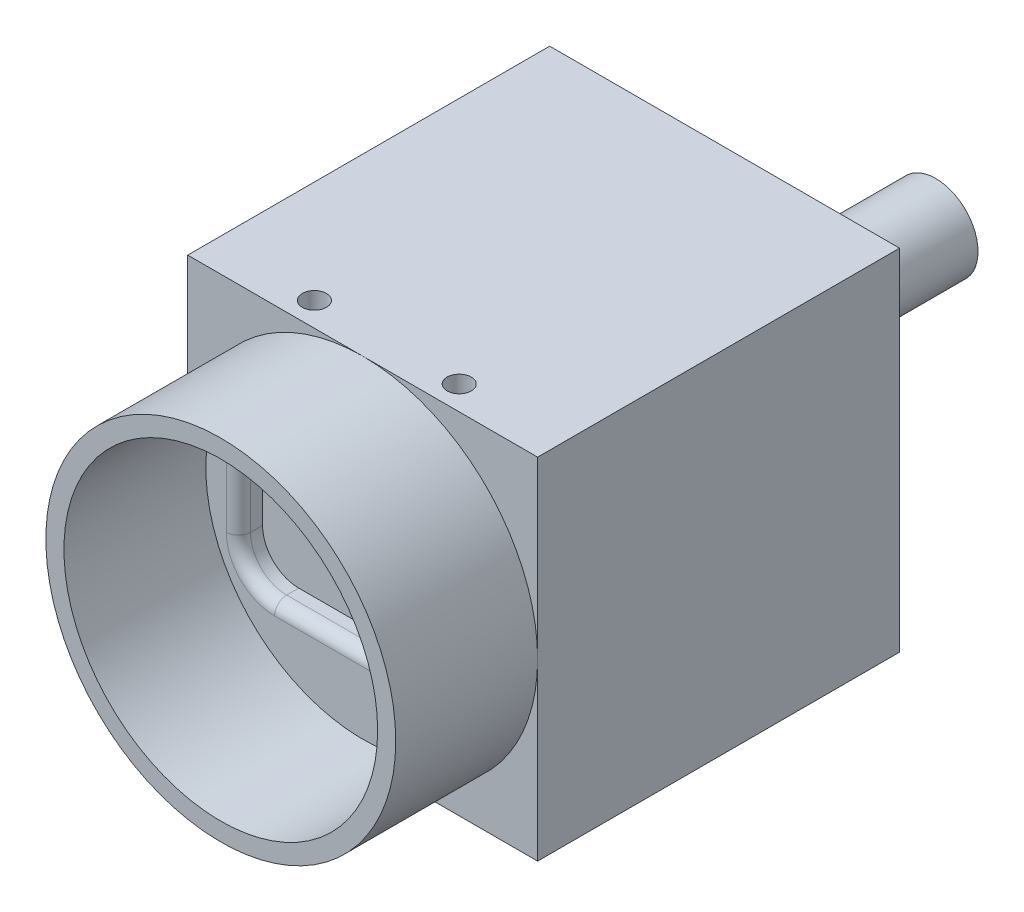
from build123d import *

# Parameters (mm, degrees)
SKETCH1_W           = 29
SKETCH1_H           = 29
BOSS_EXTRUDE1_DEPTH = 30
SKETCH2_R           = 14.5
SKETCH2_R_2         = 13
BOSS_EXTRUDE2_DEPTH = 11.76
SKETCH4_W           = 20.6
SKETCH4_H           = 13.6
CUT_EXTRUDE1_DEPTH  = 2
FILLET1_R           = 3
FILLET2_R           = 1
SKETCH5_R           = 3.5
SKETCH5_R_2         = 2.5
BOSS_EXTRUDE3_DEPTH = 8
SKETCH6_R           = 1
CUT_EXTRUDE2_DEPTH  = 3
SKETCH8_R           = 1.5
SKETCH8_R_2         = 1
CUT_EXTRUDE3_DEPTH  = 2
SKETCH9_W           = 22
SKETCH9_H           = 6
BOSS_EXTRUDE4_DEPTH = 1
SKETCH10_R          = 1
CUT_EXTRUDE4_DEPTH  = 2


with BuildPart() as part:
    # Sketch1 → Boss-Extrude1 (new body)
    with BuildSketch(Plane.XY):
        with Locations((-0.780453258, -3.943342776)):
            Rectangle(SKETCH1_W, SKETCH1_H)
    extrude(amount=BOSS_EXTRUDE1_DEPTH)

    # Sketch2 → Boss-Extrude2 (add)
    with BuildSketch(Plane.XY.offset(30)):
        with Locations((-0.780453258, -3.943342776)):
            Circle(SKETCH2_R)
        with Locations((-0.780453258, -3.943342776)):
            Circle(SKETCH2_R_2, mode=Mode.SUBTRACT)
    extrude(amount=BOSS_EXTRUDE2_DEPTH)

    # Sketch4 → Cut-Extrude1 (cut)
    with BuildSketch(Plane.XY.offset(30)):
        with Locations((-0.780453258, -3.943342776)):
            Rectangle(SKETCH4_W, SKETCH4_H)
    extrude(amount=-CUT_EXTRUDE1_DEPTH, mode=Mode.SUBTRACT)

    # Fillet1
    fillet1_edges = [part.edges().sort_by_distance(p)[0] for p in [
        (-11.080453258, -10.743342776, 29),
        (-11.080453258, 2.856657224, 29),
        (9.519546742, 2.856657224, 29),
        (9.519546742, -10.743342776, 29),
    ]]
    fillet(fillet1_edges, radius=FILLET1_R)

    # Fillet2
    fillet2_edges = [part.edges().sort_by_distance(p)[0] for p in [
        (-0.780453258, -10.743342776, 30),
        (-11.080453258, -3.943342776, 30),
        (9.519546742, -3.943342776, 30),
        (-0.780453258, 2.856657224, 30),
        (-10.201773601, -9.86466312, 30),
        (8.640867086, -9.86466312, 30),
        (8.640867086, 1.977977567, 30),
        (-10.201773601, 1.977977567, 30),
    ]]
    fillet(fillet2_edges, radius=FILLET2_R)

    # Sketch5 → Boss-Extrude3 (add)
    with BuildSketch(Plane(origin=(0, 0, 0), x_dir=(-1, 0, 0), z_dir=(0, 0, -1))):
        with Locations((-8.719546742, 5.556657224)):
            Circle(SKETCH5_R)
        with Locations((-8.719546742, 5.556657224)):
            Circle(SKETCH5_R_2, mode=Mode.SUBTRACT)
    extrude(amount=BOSS_EXTRUDE3_DEPTH)

    # Sketch6 → Cut-Extrude2 (cut)
    with BuildSketch(Plane(origin=(0, 10.556657224, 0), x_dir=(1, 0, 0), z_dir=(0, 1, 0))):
        with Locations((-6.780453258, -28)):
            Circle(SKETCH6_R)
        with Locations((5.219546742, -28)):
            Circle(SKETCH6_R)
    extrude(amount=-CUT_EXTRUDE2_DEPTH, mode=Mode.SUBTRACT)

    # Sketch8 → Cut-Extrude3 (cut)
    with BuildSketch(Plane.XZ.offset(18.443342776)):
        with Locations((9.219546742, 27)):
            Circle(SKETCH8_R)
        with Locations((-10.780453258, 27)):
            Circle(SKETCH8_R)
        with Locations((-6.780453258, 25.5)):
            Circle(SKETCH8_R_2)
        with Locations((5.219546742, 25.5)):
            Circle(SKETCH8_R_2)
        with Locations((-6.780453258, 3.5)):
            Circle(SKETCH8_R_2)
        with Locations((5.219546742, 3.5)):
            Circle(SKETCH8_R_2)
        with Locations((-0.780453258, 3.5)):
            Circle(SKETCH8_R)
        with BuildLine():
            Line((-12.280453258, 22.292576019), (10.719546742, 22.292576019))
            ThreePointArc((10.719546742, 22.292576019), (11.426653523, 21.999682801), (11.719546742, 21.292576019))
            Line((11.719546742, 21.292576019), (11.719546742, 7.292576019))
            ThreePointArc((11.719546742, 7.292576019), (11.426653523, 6.585469238), (10.719546742, 6.292576019))
            Line((10.719546742, 6.292576019), (-12.280453258, 6.292576019))
            ThreePointArc((-12.280453258, 6.292576019), (-12.987560039, 6.585469238), (-13.280453258, 7.292576019))
            Line((-13.280453258, 7.292576019), (-13.280453258, 21.292576019))
            ThreePointArc((-13.280453258, 21.292576019), (-12.987560039, 21.999682801), (-12.280453258, 22.292576019))
        make_face()
    extrude(amount=-CUT_EXTRUDE3_DEPTH, mode=Mode.SUBTRACT)

    # Sketch9 → Boss-Extrude4 (add)
    with BuildSketch(Plane(origin=(0, 0, 0), x_dir=(-1, 0, 0), z_dir=(0, 0, -1))):
        with Locations((1.280453258, -13.443342776)):
            Rectangle(SKETCH9_W, SKETCH9_H)
    extrude(amount=BOSS_EXTRUDE4_DEPTH)

    # Sketch10 → Cut-Extrude4 (cut)
    with BuildSketch(Plane(origin=(0, 0, -1), x_dir=(-1, 0, 0), z_dir=(0, 0, -1))):
        with Locations((-7.719546742, -13.443342776)):
            Circle(SKETCH10_R)
        with Locations((10.280453258, -13.443342776)):
            Circle(SKETCH10_R)
    extrude(amount=-CUT_EXTRUDE4_DEPTH, mode=Mode.SUBTRACT)


solid = part.part
